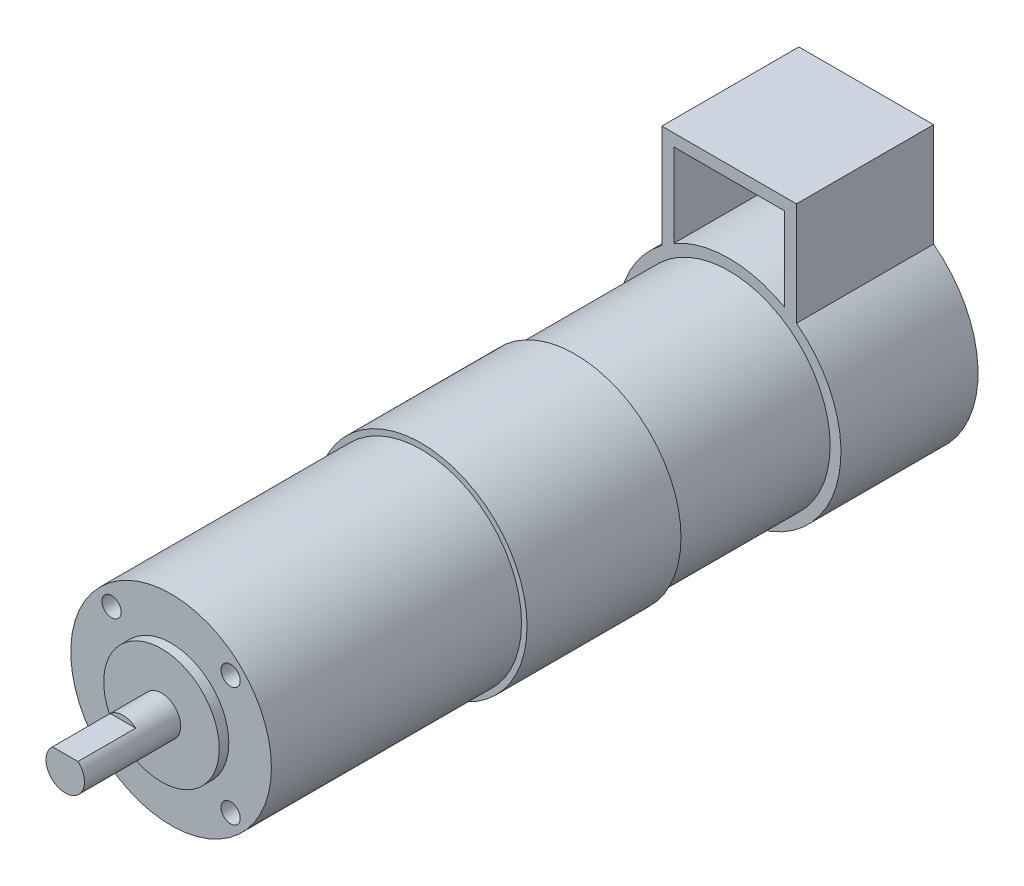
from build123d import *

# Parameters (mm, degrees)
BOSS_EXTRUDE1_DEPTH      = 16
BOSS_EXTRUDE1_DEPTH_BACK = 16
SKETCH1_R                = 22
SKETCH2_R                = 20.85
BOSS_EXTRUDE2_DEPTH      = 8
SKETCH3_R                = 20.85
BOSS_EXTRUDE3_DEPTH      = 44
SKETCH4_R                = 21
BOSS_EXTRUDE4_DEPTH      = 32
SKETCH5_R                = 23.25
BOSS_EXTRUDE5_DEPTH      = 28.5
BOSS_EXTRUDE6_START      = -28.5
BOSS_EXTRUDE6_DEPTH      = 28.5
SKETCH7_R                = 12
BOSS_EXTRUDE7_DEPTH      = 2
SKETCH8_R                = 2
CUT_EXTRUDE1_DEPTH       = 6
SKETCH9_W                = 24.120250452
SKETCH9_H                = 20.982117735
BOSS_EXTRUDE8_DEPTH      = 2
SKETCH10_R               = 4
BOSS_EXTRUDE9_DEPTH      = 20
CUT_EXTRUDE2_DEPTH       = 12


with BuildPart() as part:
    # Sketch1 → Boss-Extrude1 (new, two sides: drawn at the far end of the back side and taken through both)
    with BuildSketch(Plane.XY.offset(-BOSS_EXTRUDE1_DEPTH_BACK)):
        Circle(SKETCH1_R)
    extrude(amount=BOSS_EXTRUDE1_DEPTH + BOSS_EXTRUDE1_DEPTH_BACK)

    # Sketch2 → Boss-Extrude2 (add)
    with BuildSketch(Plane.XY.offset(16)):
        Circle(SKETCH2_R)
    extrude(amount=BOSS_EXTRUDE2_DEPTH)

    # Sketch3 → Boss-Extrude3 (add)
    with BuildSketch(Plane.XY.offset(24)):
        Circle(SKETCH3_R)
    extrude(amount=BOSS_EXTRUDE3_DEPTH)

    # Sketch4 → Boss-Extrude4 (add)
    with BuildSketch(Plane(origin=(0, 0, -16), x_dir=(-1, 0, 0), z_dir=(0, 0, -1))):
        Circle(SKETCH4_R)
    extrude(amount=BOSS_EXTRUDE4_DEPTH)

    # Sketch5 → Boss-Extrude5 (add)
    with BuildSketch(Plane(origin=(0, 0, -48), x_dir=(-1, 0, 0), z_dir=(0, 0, -1))):
        Circle(SKETCH5_R)
    extrude(amount=BOSS_EXTRUDE5_DEPTH)

    # Sketch6 → Boss-Extrude6 (add)
    with BuildSketch(Plane(origin=(0, 0, -76.5), x_dir=(-1, 0, 0), z_dir=(0, 0, -1)).offset(BOSS_EXTRUDE6_START)):
        with BuildLine():
            Line((14, 40.062394781), (-14, 40.062394781))
            Line((-14, 40.062394781), (-14, 18.562394781))
            ThreePointArc((-14, 18.562394781), (-12.776481168, 19.424830217), (-11.5, 20.206743924))
            Line((-11.5, 20.206743924), (-11.5, 37.562394781))
            Line((-11.5, 37.562394781), (11.5, 37.562394781))
            Line((11.5, 37.562394781), (11.5, 20.206743924))
            ThreePointArc((11.5, 20.206743924), (12.776481168, 19.424830217), (14, 18.562394781))
            Line((14, 18.562394781), (14, 40.062394781))
        make_face()
    extrude(amount=BOSS_EXTRUDE6_DEPTH)

    # Sketch7 → Boss-Extrude7 (add)
    with BuildSketch(Plane.XY.offset(68)):
        Circle(SKETCH7_R)
    extrude(amount=BOSS_EXTRUDE7_DEPTH)

    # Sketch8 → Cut-Extrude1 (cut)
    with BuildSketch(Plane.XY.offset(68)):
        with Locations((12.374368671, 12.374368671)):
            Circle(SKETCH8_R)
        with Locations((12.374368671, -12.374368671)):
            Circle(SKETCH8_R)
        with Locations((-12.374368671, -12.374368671)):
            Circle(SKETCH8_R)
        with Locations((-12.374368671, 12.374368671)):
            Circle(SKETCH8_R)
    extrude(amount=-CUT_EXTRUDE1_DEPTH, mode=Mode.SUBTRACT)

    # Sketch9 → Boss-Extrude8 (add)
    with BuildSketch(Plane(origin=(0, 0, -76.5), x_dir=(-1, 0, 0), z_dir=(0, 0, -1))):
        with Locations((0, 27.637719743)):
            Rectangle(SKETCH9_W, SKETCH9_H)
    extrude(amount=-BOSS_EXTRUDE8_DEPTH)

    # Sketch10 → Boss-Extrude9 (add)
    with BuildSketch(Plane.XY.offset(70)):
        Circle(SKETCH10_R)
    extrude(amount=BOSS_EXTRUDE9_DEPTH)

    # Sketch11 → Cut-Extrude2 (cut)
    with BuildSketch(Plane.XY.offset(90)):
        Polygon((0, 3), (-3.981730615, 3), (-3.981730615, 4.192756348), (4.050863087, 4.192756348), (4.050863087, 3), align=None)
    extrude(amount=-CUT_EXTRUDE2_DEPTH, mode=Mode.SUBTRACT)


solid = part.part
